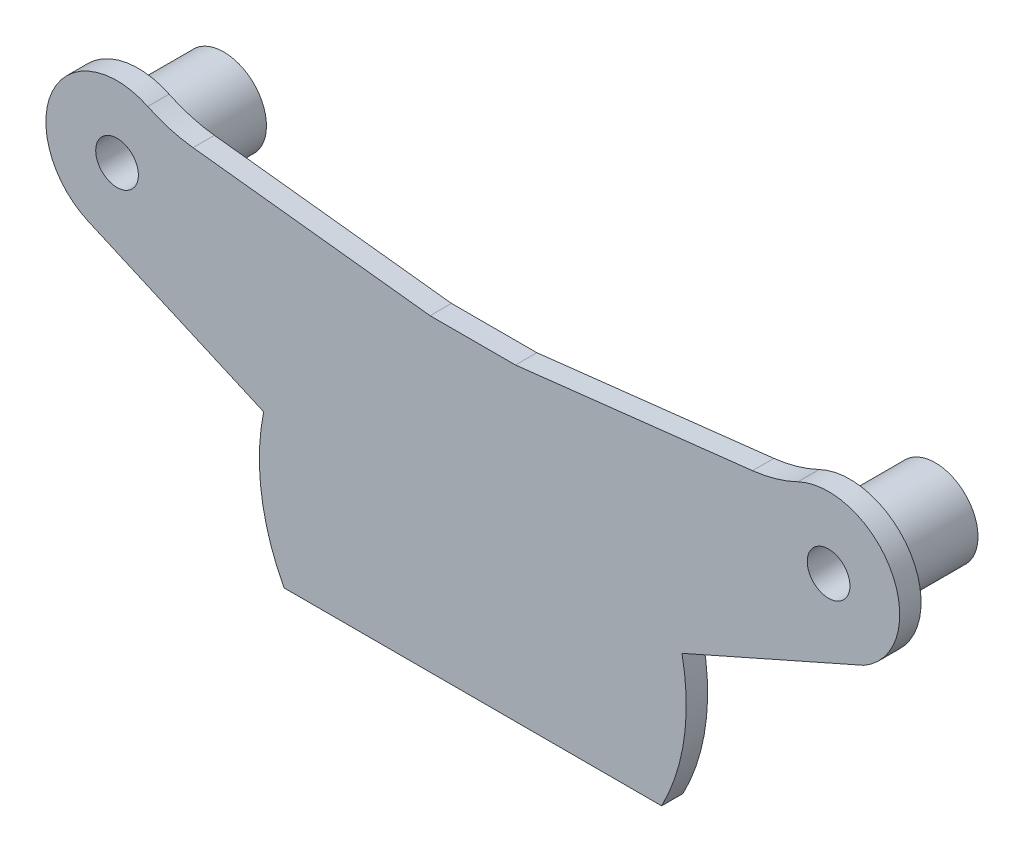
from build123d import *

# Parameters (mm, degrees)
SKETCH_1_R      = 1.5
EXTRUDE_1_DEPTH = 1.5
SKETCH_4_R      = 3
SKETCH_4_R_2    = 1.5
EXTRUDE_2_DEPTH = 6
FILLET_1_R      = 1


with BuildPart() as part:
    # Эскиз1 → Бобышка-Вытянуть1 (new body)
    with BuildSketch(Plane.XY):
        with BuildLine():
            ThreePointArc((-14.696938457, 3), (-14.848853857, -2.124038405), (-13.266499161, -7))
            Line((-13.266499161, -7), (13.266499161, -7))
            ThreePointArc((13.266499161, -7), (14.848853857, -2.124038405), (14.696938457, 3))
            Line((14.696938457, 3), (27.493638863, 8.666206601))
            ThreePointArc((27.493638863, 8.666206601), (29.425159504, 15.327651899), (22.841677521, 17.51017118))
            ThreePointArc((22.841677521, 17.51017118), (21.287556094, 16.919662188), (19.657078674, 16.594796577))
            Line((19.657078674, 16.594796577), (3, 14.696938457))
            Line((3, 14.696938457), (-3, 14.696938457))
            Line((-3, 14.696938457), (-19.657078674, 16.594796577))
            ThreePointArc((-19.657078674, 16.594796577), (-21.287556094, 16.919662188), (-22.841677521, 17.51017118))
            ThreePointArc((-22.841677521, 17.51017118), (-29.543661072, 15.086898192), (-27.014954435, 8.423980045))
            Line((-27.014954435, 8.423980045), (-14.696938457, 3))
        make_face()
        with Locations((-25, 13)):
            Circle(SKETCH_1_R, mode=Mode.SUBTRACT)
        with Locations((25, 13)):
            Circle(SKETCH_1_R, mode=Mode.SUBTRACT)
    extrude(amount=EXTRUDE_1_DEPTH)

    # Эскиз4 → Бобышка-Вытянуть2 (add)
    with BuildSketch(Plane(origin=(0, 0, 0), x_dir=(-1, 0, 0), z_dir=(0, 0, -1))):
        with Locations((25, 13)):
            Circle(SKETCH_4_R)
        with Locations((25, 13)):
            Circle(SKETCH_4_R_2, mode=Mode.SUBTRACT)
        with Locations((-25, 13)):
            Circle(SKETCH_4_R)
        with Locations((-25, 13)):
            Circle(SKETCH_4_R_2, mode=Mode.SUBTRACT)
    extrude(amount=EXTRUDE_2_DEPTH)

    # Скругление1
    fillet_1_edges = [part.edges().sort_by_distance(p)[0] for p in [
        (-22, 13, 0),
        (28, 13, 0),
    ]]
    fillet(fillet_1_edges, radius=FILLET_1_R)


solid = part.part
